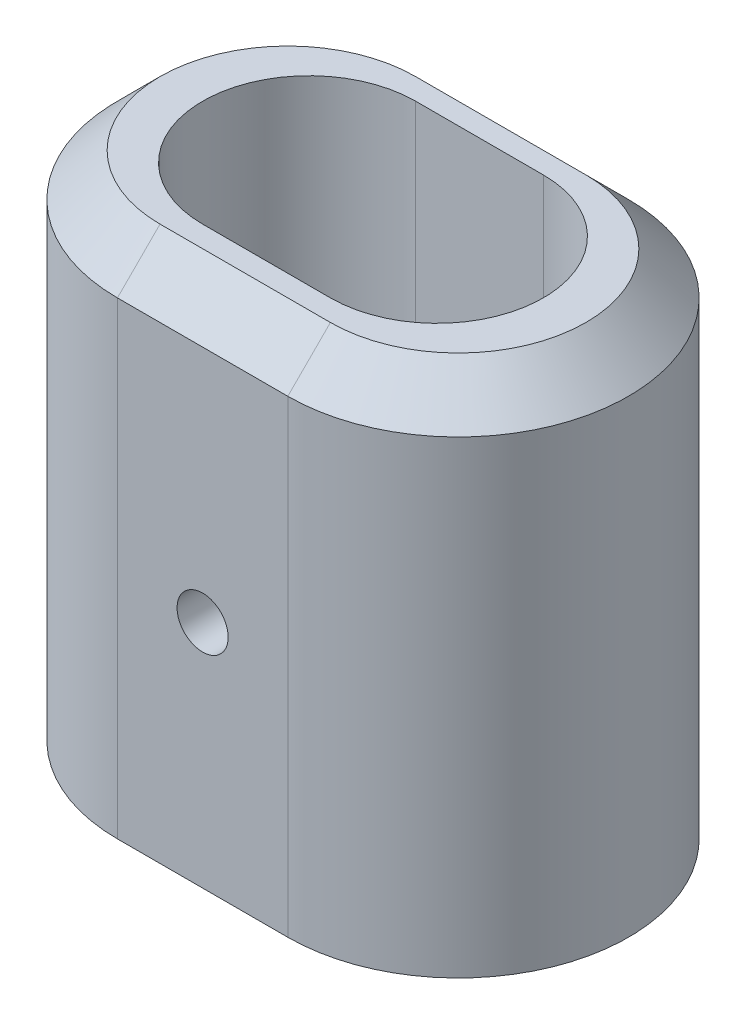
from build123d import *

# Parameters (mm, degrees)
SALIENTE_EXTRUIR1_DEPTH = 60
CHAFL_N1_SIZE           = 5
CROQUIS2_R              = 3
CORTAR_EXTRUIR1_DEPTH   = 60


with BuildPart() as part:
    # Croquis1 → Saliente-Extruir1 (new body)
    with BuildSketch(Plane(origin=(0, 0, 0), x_dir=(1, 0, 0), z_dir=(0, 1, 0))):
        with BuildLine():
            Line((-2.5, 20), (17.5, 20))
            ThreePointArc((17.5, 20), (37.5, 0), (17.5, -20))
            Line((17.5, -20), (-2.5, -20))
            ThreePointArc((-2.5, -20), (-22.5, 0), (-2.5, 20))
        make_face()
        with BuildLine():
            Line((0, 12.5), (15, 12.5))
            ThreePointArc((15, 12.5), (27.5, 0), (15, -12.5))
            Line((15, -12.5), (0, -12.5))
            ThreePointArc((0, -12.5), (-12.5, 0), (0, 12.5))
        make_face(mode=Mode.SUBTRACT)
    extrude(amount=SALIENTE_EXTRUIR1_DEPTH)

    # Chaflán1
    chafl_n1_edges = [part.edges().sort_by_distance(p)[0] for p in [
        (37.5, 60, 0),
        (7.5, 60, -20),
        (-22.5, 60, 0),
        (7.5, 60, 20),
    ]]
    chamfer(chafl_n1_edges, length=CHAFL_N1_SIZE)

    # Croquis2 → Cortar-Extruir1 (cut)
    with BuildSketch(Plane.XY.offset(20)):
        with Locations((7.5, 27)):
            Circle(CROQUIS2_R)
    extrude(amount=-CORTAR_EXTRUIR1_DEPTH, mode=Mode.SUBTRACT)


solid = part.part
